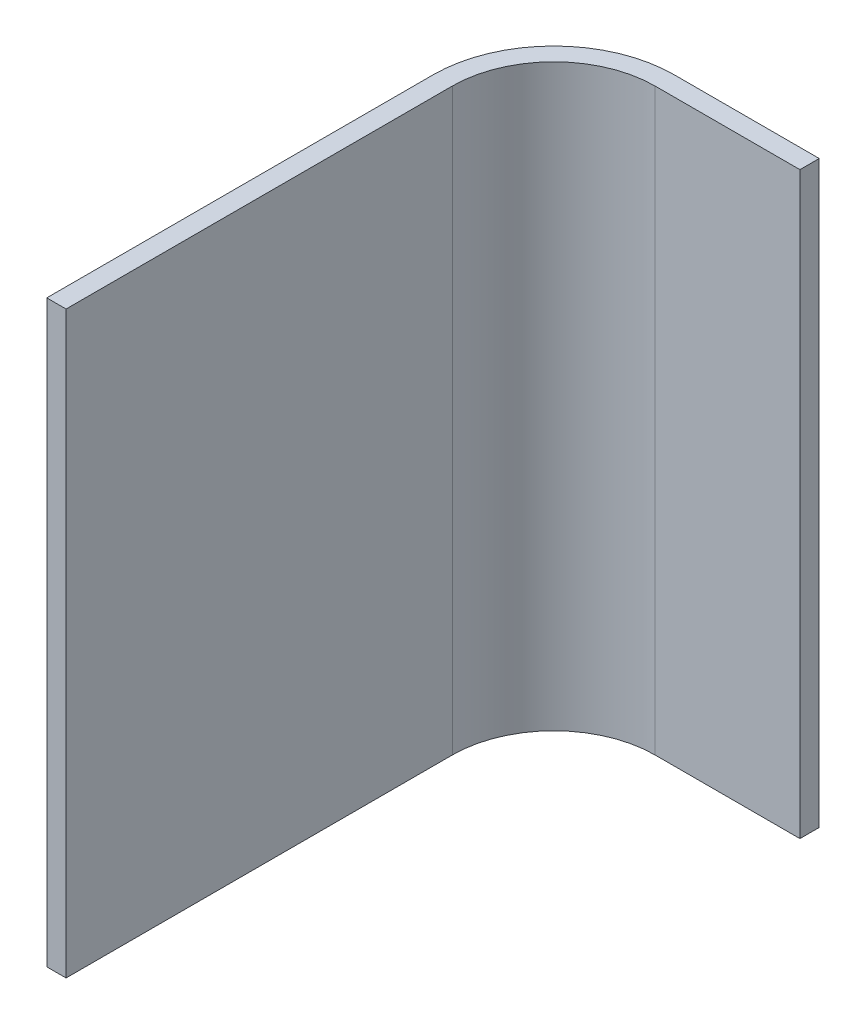
from build123d import *

# Parameters (mm, degrees)
EXTRUIR_L_MINA1_DEPTH = 120


with BuildPart() as part:
    # Croquis3 → Extruir-Lámina1 (new body)
    with BuildSketch(Plane(origin=(0, 0, 0), x_dir=(1, 0, 0), z_dir=(0, 1, 0))):
        with BuildLine():
            Line((0, 0), (0, 80))
            ThreePointArc((0, 80), (7.32233047, 97.67766953), (25, 105))
            Line((25, 105), (55, 105))
            Line((55, 105), (55, 101))
            Line((55, 101), (25, 101))
            ThreePointArc((25, 101), (10.150757595, 94.849242405), (4, 80))
            Line((4, 80), (4, 0))
            Line((4, 0), (0, 0))
        make_face()
    extrude(amount=EXTRUIR_L_MINA1_DEPTH)


solid = part.part
